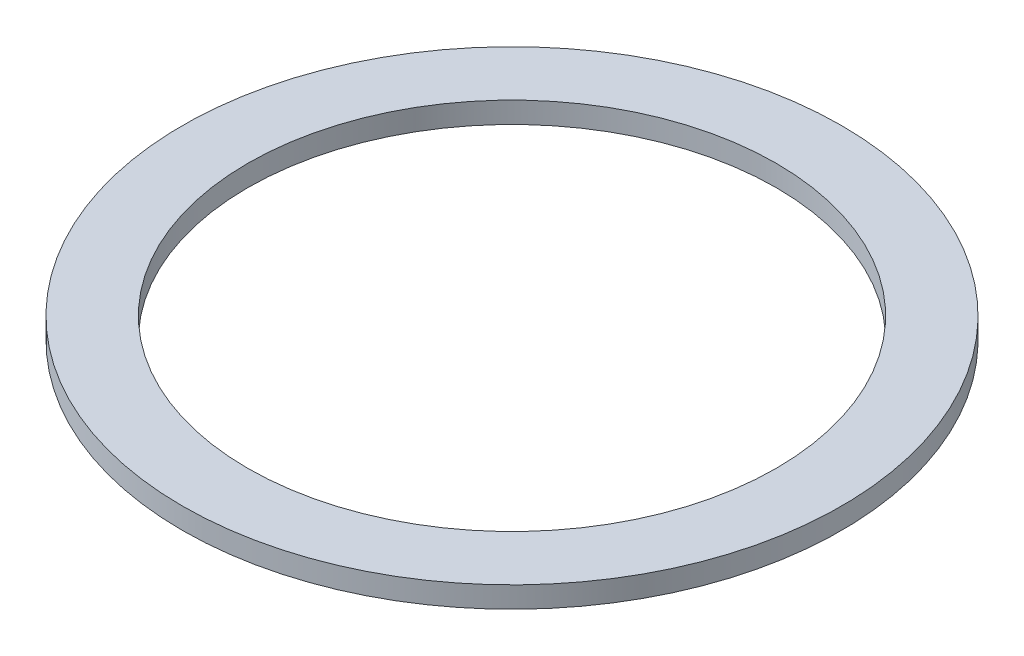
from build123d import *

# Parameters (mm, degrees)
SKETCH1_R           = 49.5046
SKETCH1_R_2         = 39.6875
BOSS_EXTRUDE1_DEPTH = 3.175


with BuildPart() as part:
    # Sketch1 → Boss-Extrude1 (new body)
    with BuildSketch(Plane(origin=(0, 0, 0), x_dir=(1, 0, 0), z_dir=(0, 1, 0))):
        Circle(SKETCH1_R)
        Circle(SKETCH1_R_2, mode=Mode.SUBTRACT)
    extrude(amount=BOSS_EXTRUDE1_DEPTH)


solid = part.part
